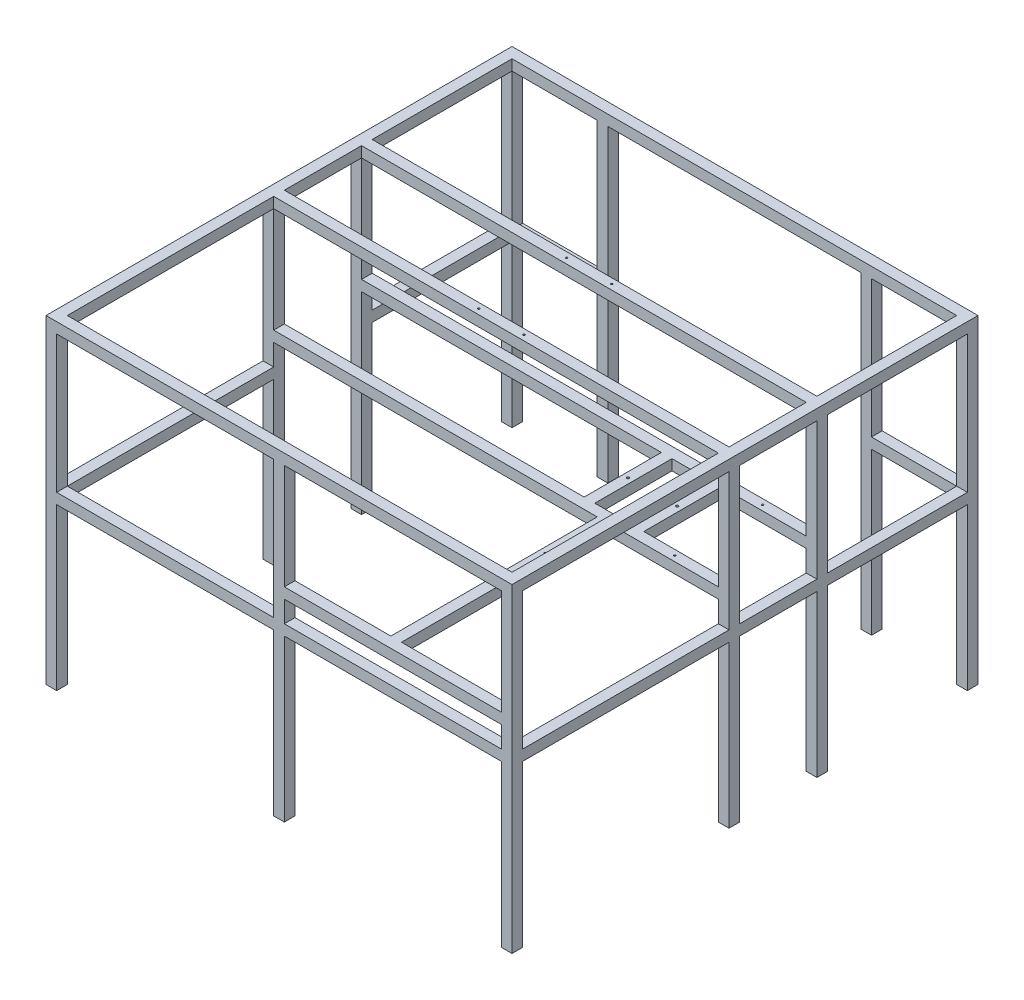
from build123d import *

# Parameters (mm, degrees)
SKETCH1_W             = 1750
SKETCH1_H             = 1750
SKETCH1_W_2           = 1670
SKETCH1_H_2           = 525
SKETCH1_H_3           = 775
BOSS_EXTRUDE1_DEPTH   = 40
SKETCH2_W             = 40
SKETCH2_H             = 40
BOSS_EXTRUDE2_DEPTH   = 1160
SKETCH3_W             = 40
SKETCH3_H             = 40
BOSS_EXTRUDE3_DEPTH   = 1710
SKETCH4_W             = 40
SKETCH4_H             = 40
BOSS_EXTRUDE4_DEPTH   = 1710
SKETCH5_W             = 40
SKETCH5_H             = 40
BOSS_EXTRUDE5_DEPTH   = 1710
SKETCH6_W             = 950
SKETCH6_H             = 40
CUT_EXTRUDE1_DEPTH    = 40
SKETCH9_W             = 290
SKETCH9_H             = 40
CUT_EXTRUDE4_DEPTH    = 40
M8_TAPPED_HOLE1_D     = 6.8
M8_TAPPED_HOLE1_DEPTH = 17.707073895
M8_TAPPED_HOLE1_TIP   = 2.042926105
SKETCH13_W            = 40
SKETCH13_H            = 40
BOSS_EXTRUDE6_DEPTH   = 1710
SKETCH15_W            = 815
SKETCH15_H            = 40
CUT_EXTRUDE5_DEPTH    = 40
SKETCH16_W            = 40
SKETCH16_H            = 40
BOSS_EXTRUDE7_DEPTH   = 815
SKETCH18_R            = 3.3
CUT_EXTRUDE6_DEPTH    = 40
SKETCH20_R            = 3.3
CUT_EXTRUDE8_DEPTH    = 40
SKETCH22_W            = 40
SKETCH22_H            = 40
BOSS_EXTRUDE8_DEPTH   = 330
SKETCH23_R            = 4.5
CUT_EXTRUDE9_DEPTH    = 40


with BuildPart() as part:
    # Sketch1 → Boss-Extrude1 (new body)
    with BuildSketch(Plane(origin=(0, 0, 0), x_dir=(1, 0, 0), z_dir=(0, 1, 0))):
        Rectangle(SKETCH1_W, SKETCH1_H)
        with Locations((0, 572.5)):
            Rectangle(SKETCH1_W_2, SKETCH1_H_2, mode=Mode.SUBTRACT)
        with Locations((0, -447.5)):
            Rectangle(SKETCH1_W_2, SKETCH1_H_3, mode=Mode.SUBTRACT)
        Polygon((-835, -20), (835, -20), (835, 20), (835, 270), (-835, 270), (-835, 20), align=None, mode=Mode.SUBTRACT)
    extrude(amount=BOSS_EXTRUDE1_DEPTH)

    # Sketch2 → Boss-Extrude2 (add)
    with BuildSketch(Plane.XZ):
        with Locations((-855, 855)):
            Rectangle(SKETCH2_W, SKETCH2_H)
        with Locations((855, 855)):
            Rectangle(SKETCH2_W, SKETCH2_H)
        with Locations((0, 855)):
            Rectangle(SKETCH2_W, SKETCH2_H)
        with Locations((855, 40)):
            Rectangle(SKETCH2_W, SKETCH2_H)
        with Locations((-855, 40)):
            Rectangle(SKETCH2_W, SKETCH2_H)
        with Locations((-855, -855)):
            Rectangle(SKETCH2_W, SKETCH2_H)
        with Locations((855, -855)):
            Rectangle(SKETCH2_W, SKETCH2_H)
        with Locations((495, -855)):
            Rectangle(SKETCH2_W, SKETCH2_H)
        with Locations((-495, -855)):
            Rectangle(SKETCH2_W, SKETCH2_H)
        with Locations((-855, -290)):
            Rectangle(SKETCH2_W, SKETCH2_H)
        with Locations((855, -290)):
            Rectangle(SKETCH2_W, SKETCH2_H)
    extrude(amount=BOSS_EXTRUDE2_DEPTH)

    # Sketch3 → Boss-Extrude3 (add)
    with BuildSketch(Plane.XY.offset(875)):
        with Locations((-855, -535)):
            Rectangle(SKETCH3_W, SKETCH3_H)
        with Locations((855, -535)):
            Rectangle(SKETCH3_W, SKETCH3_H)
    extrude(amount=-BOSS_EXTRUDE3_DEPTH)

    # Sketch4 → Boss-Extrude4 (add)
    with BuildSketch(Plane.ZY.offset(875)):
        with Locations((855, -535)):
            Rectangle(SKETCH4_W, SKETCH4_H)
    extrude(amount=-BOSS_EXTRUDE4_DEPTH)

    # Sketch5 → Boss-Extrude5 (add)
    with BuildSketch(Plane.ZY.offset(875)):
        with Locations((-855, -535)):
            Rectangle(SKETCH5_W, SKETCH5_H)
    extrude(amount=-BOSS_EXTRUDE5_DEPTH)

    # Sketch6 → Cut-Extrude1 (cut)
    with BuildSketch(Plane(origin=(0, 0, -875), x_dir=(-1, 0, 0), z_dir=(0, 0, -1))):
        with Locations((0, -535)):
            Rectangle(SKETCH6_W, SKETCH6_H)
    extrude(amount=-CUT_EXTRUDE1_DEPTH, mode=Mode.SUBTRACT)

    # Sketch9 → Cut-Extrude4 (cut)
    with BuildSketch(Plane.ZY.offset(875)):
        with Locations((-125, -535)):
            Rectangle(SKETCH9_W, SKETCH9_H)
    extrude(amount=-CUT_EXTRUDE4_DEPTH, mode=Mode.SUBTRACT)

    # M8 Tapped Hole1
    with Locations(Plane(origin=(0, 40, 0), x_dir=(1, 0, 0), z_dir=(0, 1, 0))):
        with Locations((85, -40), (-85, -40), (-85, 290), (85, 290)):
            Hole(M8_TAPPED_HOLE1_D / 2, depth=M8_TAPPED_HOLE1_DEPTH)
            with Locations((0, 0, -(M8_TAPPED_HOLE1_DEPTH + M8_TAPPED_HOLE1_TIP / 2))):  # 118° drill point
                Cone(0, M8_TAPPED_HOLE1_D / 2, M8_TAPPED_HOLE1_TIP, mode=Mode.SUBTRACT)

    # Sketch13 → Boss-Extrude6 (add)
    with BuildSketch(Plane(origin=(875, 0, 0), x_dir=(0, 0, -1), z_dir=(1, 0, 0))):
        with Locations((-40, -415)):
            Rectangle(SKETCH13_W, SKETCH13_H)
        with Locations((290, -415)):
            Rectangle(SKETCH13_W, SKETCH13_H)
        with Locations((-855, -415)):
            Rectangle(SKETCH13_W, SKETCH13_H)
    extrude(amount=-BOSS_EXTRUDE6_DEPTH)

    # Sketch15 → Cut-Extrude5 (cut)
    with BuildSketch(Plane.XY.offset(875)):
        with Locations((-427.5, -415)):
            Rectangle(SKETCH15_W, SKETCH15_H)
    extrude(amount=-CUT_EXTRUDE5_DEPTH, mode=Mode.SUBTRACT)

    # Sketch16 → Boss-Extrude7 (add)
    with BuildSketch(Plane.XY.offset(875)):
        with Locations((400, -415)):
            Rectangle(SKETCH16_W, SKETCH16_H)
    extrude(amount=-BOSS_EXTRUDE7_DEPTH)

    # Sketch18 → Cut-Extrude6 (cut)
    with BuildSketch(Plane(origin=(0, -395, 0), x_dir=(1, 0, 0), z_dir=(0, 1, 0))):
        with Locations((400, -275)):
            Circle(SKETCH18_R)
    extrude(amount=-CUT_EXTRUDE6_DEPTH, mode=Mode.SUBTRACT)

    # Sketch20 → Cut-Extrude8 (cut)
    with BuildSketch(Plane(origin=(0, -395, 0), x_dir=(1, 0, 0), z_dir=(0, 1, 0))):
        with Locations((651.445575403, -40)):
            Circle(SKETCH20_R)
        with Locations((651.445575403, 290)):
            Circle(SKETCH20_R)
    extrude(amount=-CUT_EXTRUDE8_DEPTH, mode=Mode.SUBTRACT)

    # Sketch22 → Boss-Extrude8 (add)
    with BuildSketch(Plane.XY.offset(60)):
        with Locations((495, -415)):
            Rectangle(SKETCH22_W, SKETCH22_H)
        with Locations((310.857864376, -415)):
            Rectangle(SKETCH22_W, SKETCH22_H)
    extrude(amount=-BOSS_EXTRUDE8_DEPTH)

    # Sketch23 → Cut-Extrude9 (cut)
    with BuildSketch(Plane(origin=(0, -395, 0), x_dir=(1, 0, 0), z_dir=(0, 1, 0))):
        with Locations((310.857864376, 125)):
            Circle(SKETCH23_R)
        with Locations((495, 125)):
            Circle(SKETCH23_R)
    extrude(amount=-CUT_EXTRUDE9_DEPTH, mode=Mode.SUBTRACT)


solid = part.part
